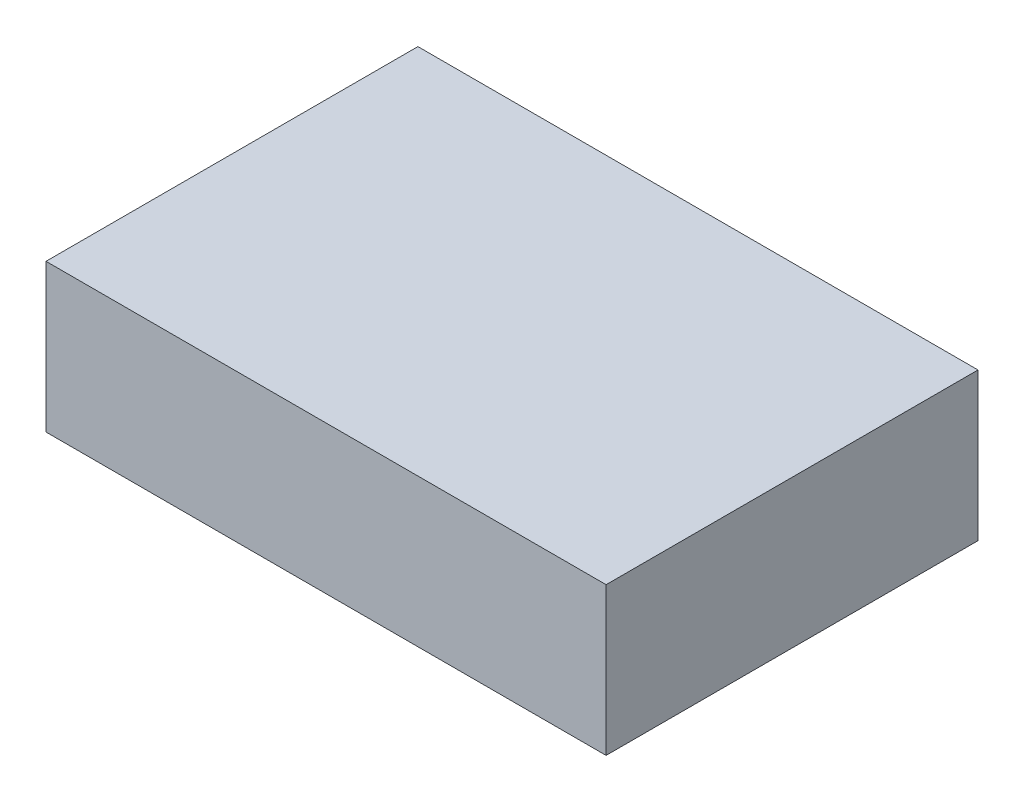
from build123d import *

# Parameters (mm, degrees)
SKETCH_1_W      = 125
SKETCH_1_H      = 83
EXTRUDE_1_DEPTH = 33


with BuildPart() as part:
    # 草图1 → 凸台-拉伸1 (new body)
    with BuildSketch(Plane(origin=(0, 0, 0), x_dir=(1, 0, 0), z_dir=(0, 1, 0))):
        Rectangle(SKETCH_1_W, SKETCH_1_H)
    extrude(amount=EXTRUDE_1_DEPTH)


solid = part.part
